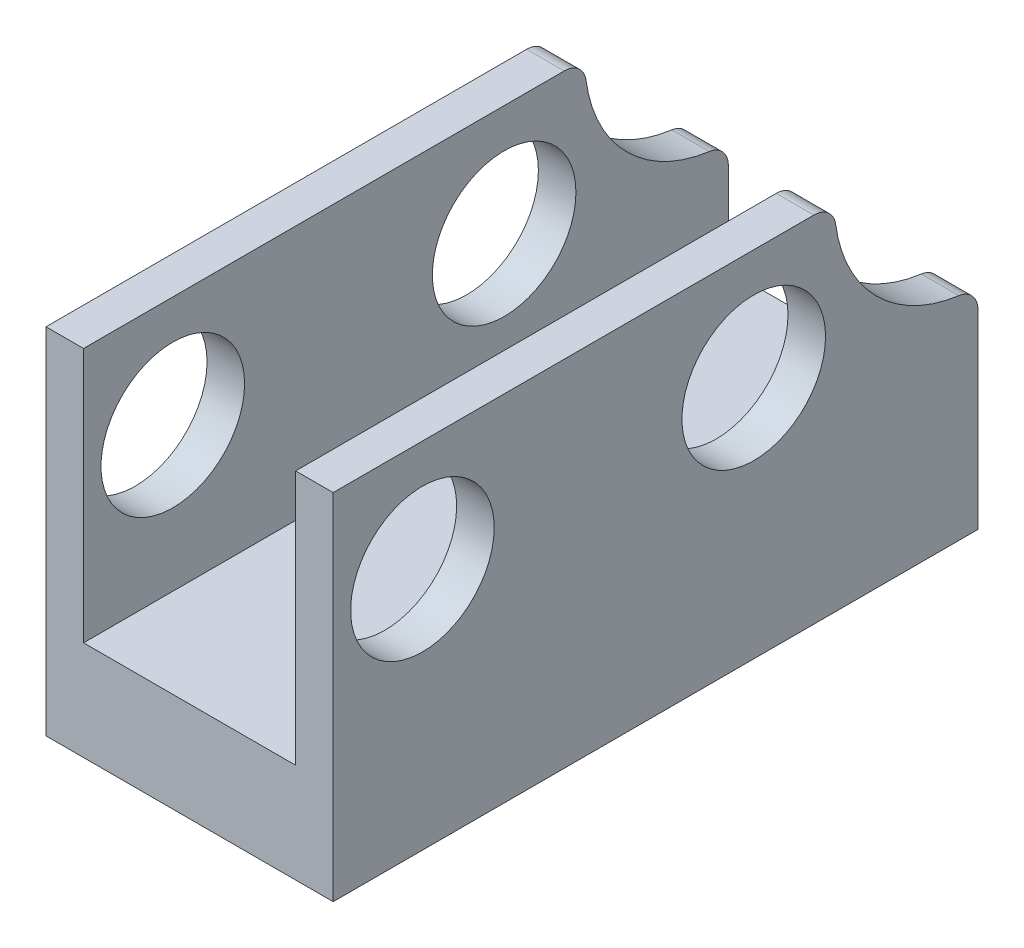
from build123d import *

# Parameters (mm, degrees)
SKETCH1_W               = 14.59562339
SKETCH1_H               = 8.02
SKETCH1_R               = 1.625
BOSS_EXTRUDE1_DEPTH     = 3.25
SKETCH2_W               = 14.59562339
SKETCH2_H               = 5.77
CUT_EXTRUDE1_DEPTH      = 2.4
CUT_EXTRUDE2_DEPTH      = 4.25
CUT_EXTRUDE2_DEPTH_BACK = 4.25
FILLET1_R               = 0.5


with BuildPart() as part:
    # Sketch1 → Boss-Extrude1 (new body, symmetric)
    with BuildSketch(Plane(origin=(0, 0, 0), x_dir=(0, 0, -1), z_dir=(1, 0, 0))):
        Rectangle(SKETCH1_W, SKETCH1_H)
        with Locations((-5.277811695, 1.5)):
            Circle(SKETCH1_R, mode=Mode.SUBTRACT)
        with Locations((2.222188305, 1.5)):
            Circle(SKETCH1_R, mode=Mode.SUBTRACT)
    extrude(amount=BOSS_EXTRUDE1_DEPTH, both=True)

    # Sketch2 → Cut-Extrude1 (cut, symmetric)
    with BuildSketch(Plane(origin=(0, 0, 0), x_dir=(0, 0, -1), z_dir=(1, 0, 0))):
        with Locations((0, 1.125)):
            Rectangle(SKETCH2_W, SKETCH2_H)
    extrude(amount=CUT_EXTRUDE1_DEPTH, both=True, mode=Mode.SUBTRACT)

    # Sketch4 → Cut-Extrude2 (cut, two sides)
    with BuildSketch(Plane(origin=(0, 0, 0), x_dir=(0, 0, -1), z_dir=(1, 0, 0))) as cut_extrude2_sk:
        with BuildLine():
            Line((4.047811695, 4.01), (7.297811695, 4.01))
            Line((7.297811695, 4.01), (7.297811695, 0.76))
            ThreePointArc((7.297811695, 0.76), (4.999714656, 1.711902961), (4.047811695, 4.01))
        make_face()
    extrude(amount=CUT_EXTRUDE2_DEPTH, mode=Mode.SUBTRACT)
    extrude(cut_extrude2_sk.sketch, amount=-CUT_EXTRUDE2_DEPTH_BACK, mode=Mode.SUBTRACT)

    # Fillet1
    fillet1_edges = [part.edges().sort_by_distance(p)[0] for p in [
        (2.825, 0.76, -7.297811695),
        (2.825, 4.01, -4.047811695),
        (-2.825, 0.76, -7.297811695),
        (-2.825, 4.01, -4.047811695),
    ]]
    fillet(fillet1_edges, radius=FILLET1_R)


solid = part.part
